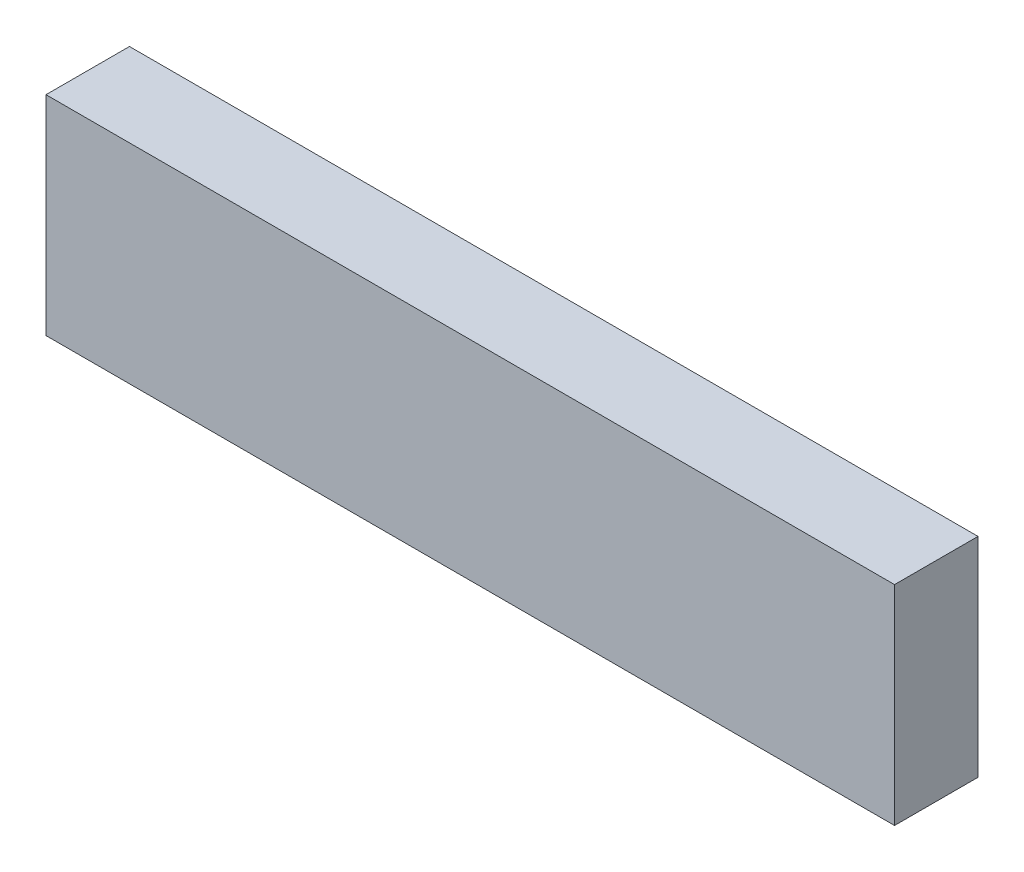
from build123d import *

# Parameters (mm, degrees)
SKETCH1_W           = 12
SKETCH1_H           = 30
BOSS_EXTRUDE1_DEPTH = 61


with BuildPart() as part:
    # Sketch1 → Boss-Extrude1 (new body, symmetric)
    with BuildSketch(Plane(origin=(0, 0, 0), x_dir=(0, 0, -1), z_dir=(1, 0, 0))):
        Rectangle(SKETCH1_W, SKETCH1_H)
    extrude(amount=BOSS_EXTRUDE1_DEPTH, both=True)


solid = part.part
